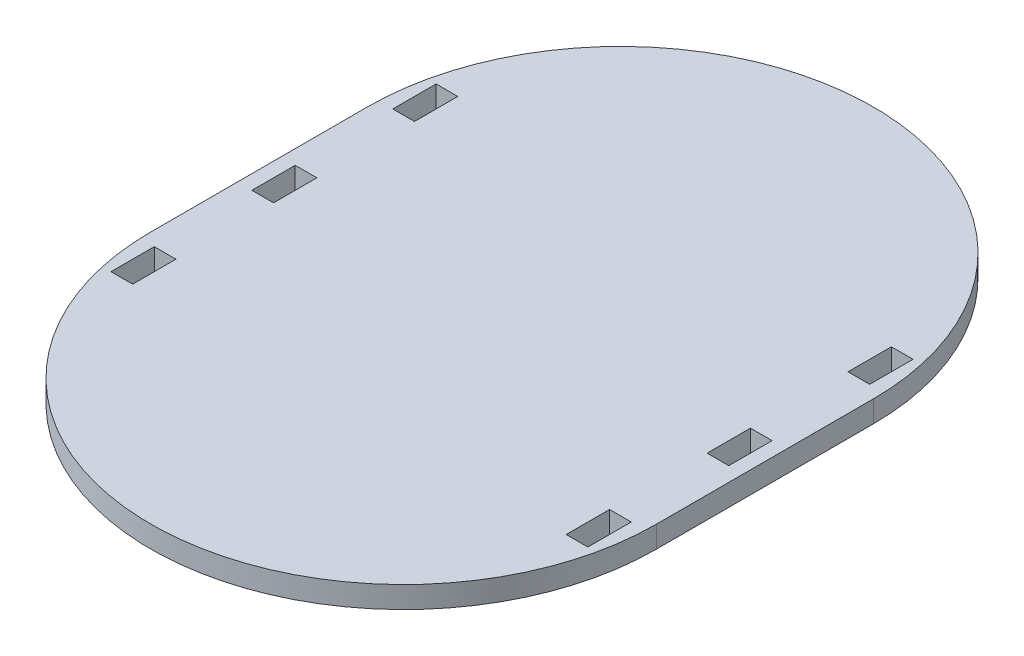
from build123d import *

# Parameters (mm, degrees)
BOSS_EXTRUDE1_DEPTH = 7.62
SKETCH5_W           = 7.62
SKETCH5_H           = 15.24
CUT_EXTRUDE5_DEPTH  = 8.62


with BuildPart() as part:
    # Sketch1 → Boss-Extrude1 (new body)
    with BuildSketch(Plane(origin=(0, 0, 0), x_dir=(1, 0, 0), z_dir=(0, 1, 0))):
        with BuildLine():
            Line((-88.9, 0), (-88.9, 76.2))
            ThreePointArc((-88.9, 76.2), (0, 165.1), (88.9, 76.2))
            Line((88.9, 76.2), (88.9, 0))
            ThreePointArc((88.9, 0), (0, -88.9), (-88.9, 0))
        make_face()
    extrude(amount=BOSS_EXTRUDE1_DEPTH)

    # Sketch5 → Cut-Extrude5 (cut, through all)
    with BuildSketch(Plane(origin=(0, 7.62, 0), x_dir=(1, 0, 0), z_dir=(0, 1, 0))):
        with Locations((80.01, -11.43)):
            Rectangle(SKETCH5_W, SKETCH5_H)
        with Locations((-80.01, -11.43)):
            Rectangle(SKETCH5_W, SKETCH5_H)
        with Locations((-80.01, 87.63)):
            Rectangle(SKETCH5_W, SKETCH5_H)
        with Locations((80.01, 87.63)):
            Rectangle(SKETCH5_W, SKETCH5_H)
        with Locations((80.01, 38.1)):
            Rectangle(SKETCH5_W, SKETCH5_H)
        with Locations((-80.01, 38.1)):
            Rectangle(SKETCH5_W, SKETCH5_H)
    extrude(amount=-CUT_EXTRUDE5_DEPTH, mode=Mode.SUBTRACT)


solid = part.part
